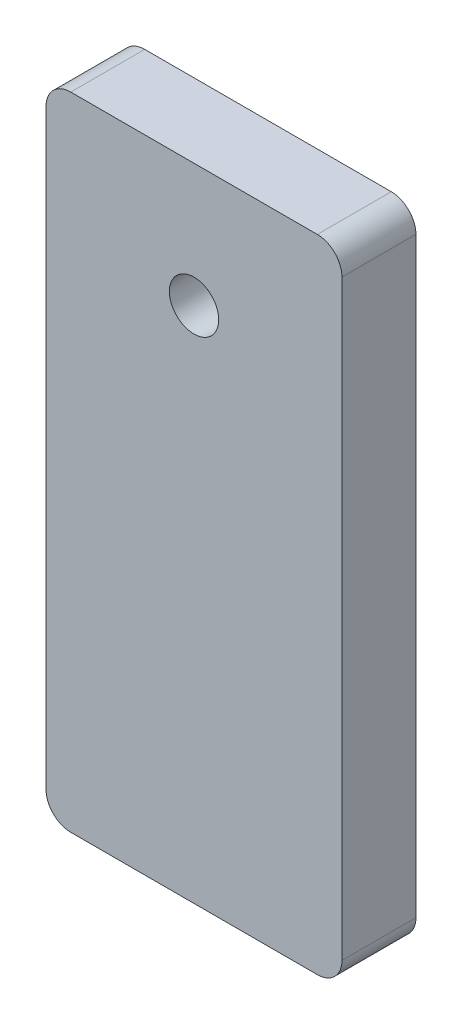
from build123d import *

# Parameters (mm, degrees)
SKETCH3_R           = 1
BOSS_EXTRUDE1_DEPTH = 3


with BuildPart() as part:
    # Sketch3 → Boss-Extrude1 (new body)
    with BuildSketch(Plane.XY):
        with BuildLine():
            Line((-5, 0), (5, 0))
            ThreePointArc((5, 0), (5.707106781, -0.292893219), (6, -1))
            Line((6, -1), (6, -25))
            ThreePointArc((6, -25), (5.707106781, -25.707106781), (5, -26))
            Line((5, -26), (-5, -26))
            ThreePointArc((-5, -26), (-5.707106781, -25.707106781), (-6, -25))
            Line((-6, -25), (-6, -1))
            ThreePointArc((-6, -1), (-5.707106781, -0.292893219), (-5, 0))
        make_face()
        with Locations((0, -5)):
            Circle(SKETCH3_R, mode=Mode.SUBTRACT)
    extrude(amount=BOSS_EXTRUDE1_DEPTH)


solid = part.part
